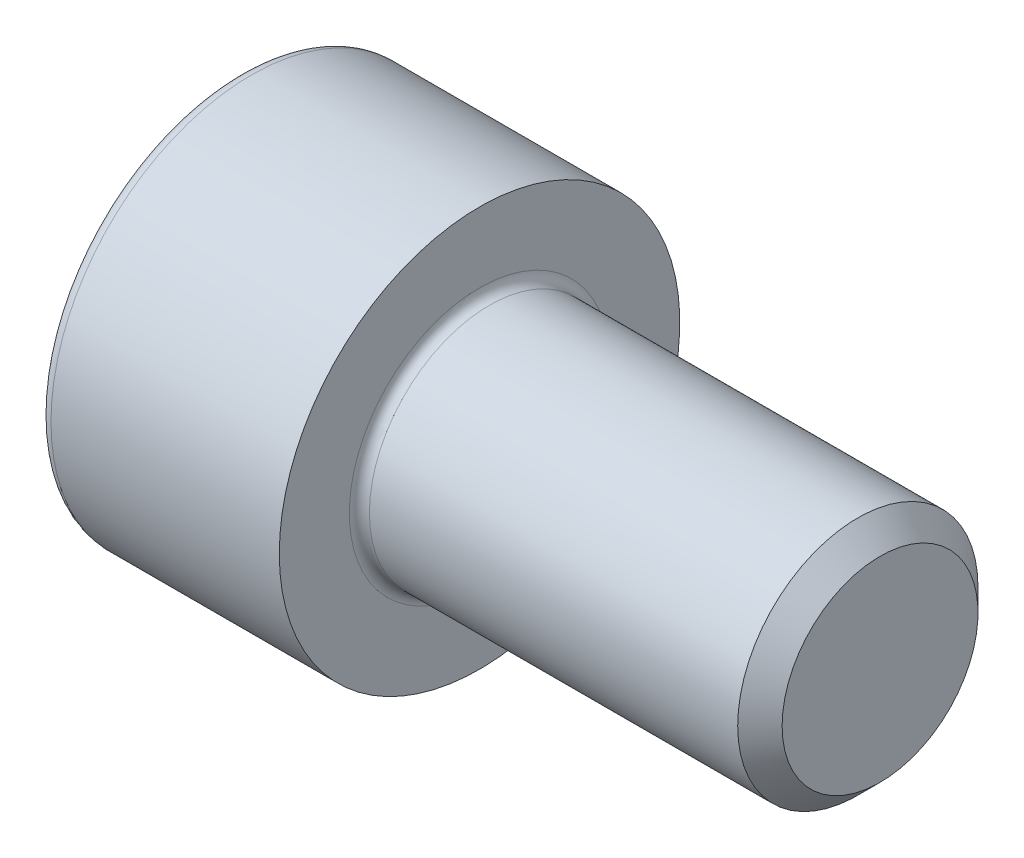
from build123d import *

# Parameters (mm, degrees)
FILLET1_R   = 0.25
FILLET2_R   = 0.3
HEX_2_DEPTH = 3


with BuildPart() as part:
    # BodySke → Base-Revolve (revolve)
    with BuildSketch(Plane.XY):
        Polygon((0, 0), (0, 5), (6, 5), (6, 3), (15.4455, 3), (16, 2.4455), (16, 0), align=None)
    revolve(axis=Axis((-31.75, 0, 0), (1, 0, 0)))

    # Fillet1
    fillet1_edges = [part.edges().sort_by_distance(p)[0] for p in [
        (6, -3, 0),
    ]]
    fillet(fillet1_edges, radius=FILLET1_R)

    # Fillet2
    fillet2_edges = [part.edges().sort_by_distance(p)[0] for p in [
        (0, -5, 0),
    ]]
    fillet(fillet2_edges, radius=FILLET2_R)

    # Sketch2 → Hex-PreBroach (revolve, cut)
    with BuildSketch(Plane.XY):
        Polygon((0, 2.542), (3, 2.542), (4.467624384, 0), (0, 0), align=None)
    revolve(axis=Axis((0, 0, 0), (1, 0, 0)), mode=Mode.SUBTRACT)

    # Sketch3 → Hex 2 (cut)
    with BuildSketch(Plane(origin=(0, 0, 0), x_dir=(0, 0.5, 0.866025404), z_dir=(-1, 0, 0))):
        Polygon((1.467624384, 2.542), (-1.467624384, 2.542), (-2.935248769, 0), (-1.467624384, -2.542), (1.467624384, -2.542), (2.935248769, 0), align=None)
    extrude(amount=-HEX_2_DEPTH, mode=Mode.SUBTRACT)


solid = part.part
